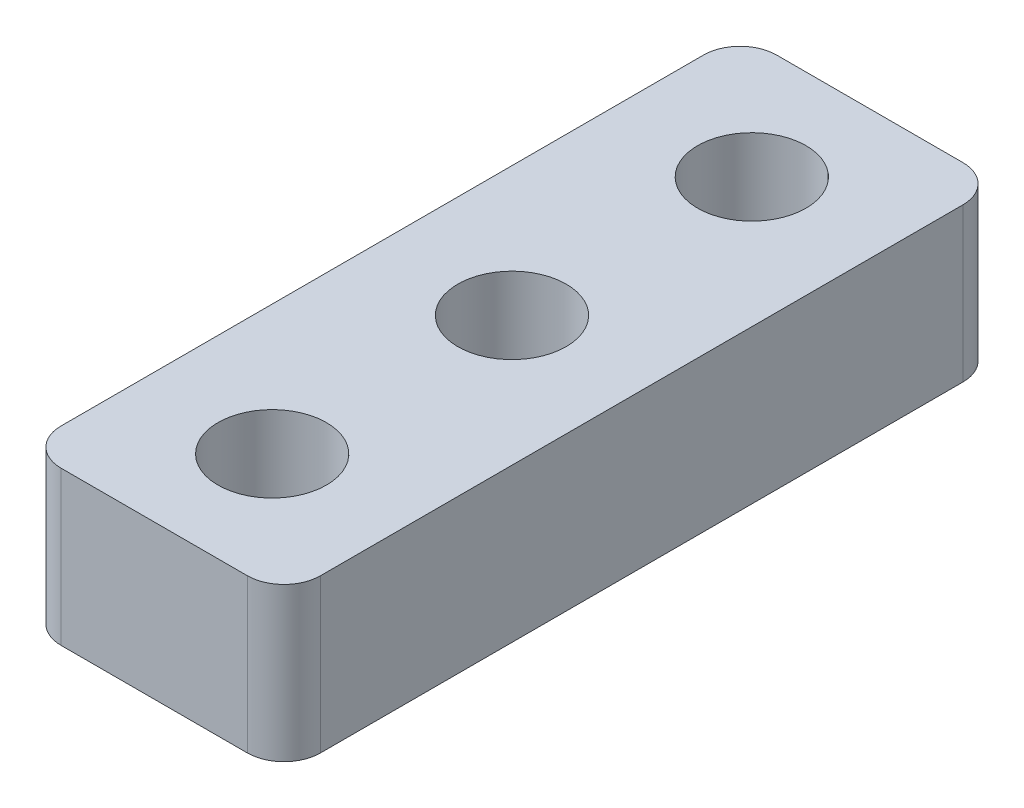
from build123d import *

# Parameters (mm, degrees)
SKETCH1_W           = 5.409
SKETCH1_H           = 3.2004
BOSS_EXTRUDE1_DEPTH = 7.459999939
SKETCH3_R           = 1.1303
CUT_EXTRUDE1_DEPTH  = 3.2004
FILLET1_R           = 0.762


with BuildPart() as part:
    # Sketch1 → Boss-Extrude1 (new body, symmetric)
    with BuildSketch(Plane.XY):
        with Locations((2.7045, 1.6002)):
            Rectangle(SKETCH1_W, SKETCH1_H)
    extrude(amount=BOSS_EXTRUDE1_DEPTH, both=True)

    # Sketch3 → Cut-Extrude1 (cut)
    with BuildSketch(Plane.XZ):
        with Locations((2.7045, 4.999999969)):
            Circle(SKETCH3_R)
        with Locations((2.7045, -4.999999969)):
            Circle(SKETCH3_R)
        with Locations((2.7045, 0)):
            Circle(SKETCH3_R)
    extrude(amount=-CUT_EXTRUDE1_DEPTH, mode=Mode.SUBTRACT)

    # Fillet1
    fillet1_edges = [part.edges().sort_by_distance(p)[0] for p in [
        (5.409, 1.6002, 7.459999939),
        (5.409, 1.6002, -7.459999939),
        (0, 1.6002, -7.459999939),
        (0, 1.6002, 7.459999939),
    ]]
    fillet(fillet1_edges, radius=FILLET1_R)


solid = part.part
